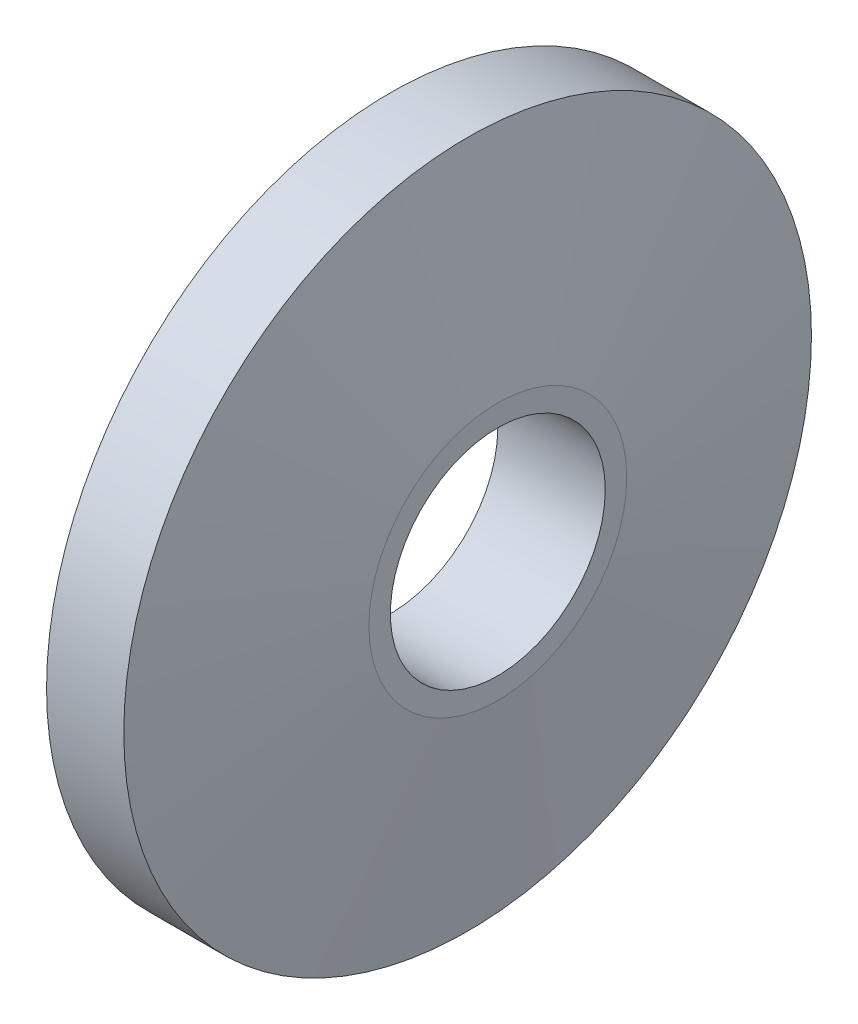
from build123d import *

# Parameters (mm, degrees)
SKETCH5_R          = 2.5
CUT_EXTRUDE3_DEPTH = 3.5


with BuildPart() as part:
    # Sketch1 → Revolve1 (revolve)
    with BuildSketch(Plane.XY):
        Polygon((0, 0), (0, 8), (1.797295826, 8), (2.5, 3), (2.5, 0), align=None)
    revolve(axis=Axis((-13.276595745, 0, 0), (1, 0, 0)))

    # Sketch5 → Cut-Extrude3 (cut, through all)
    with BuildSketch(Plane(origin=(2.5, 0, 0), x_dir=(0, 0, -1), z_dir=(1, 0, 0))):
        Circle(SKETCH5_R)
    extrude(amount=-CUT_EXTRUDE3_DEPTH, mode=Mode.SUBTRACT)


solid = part.part
